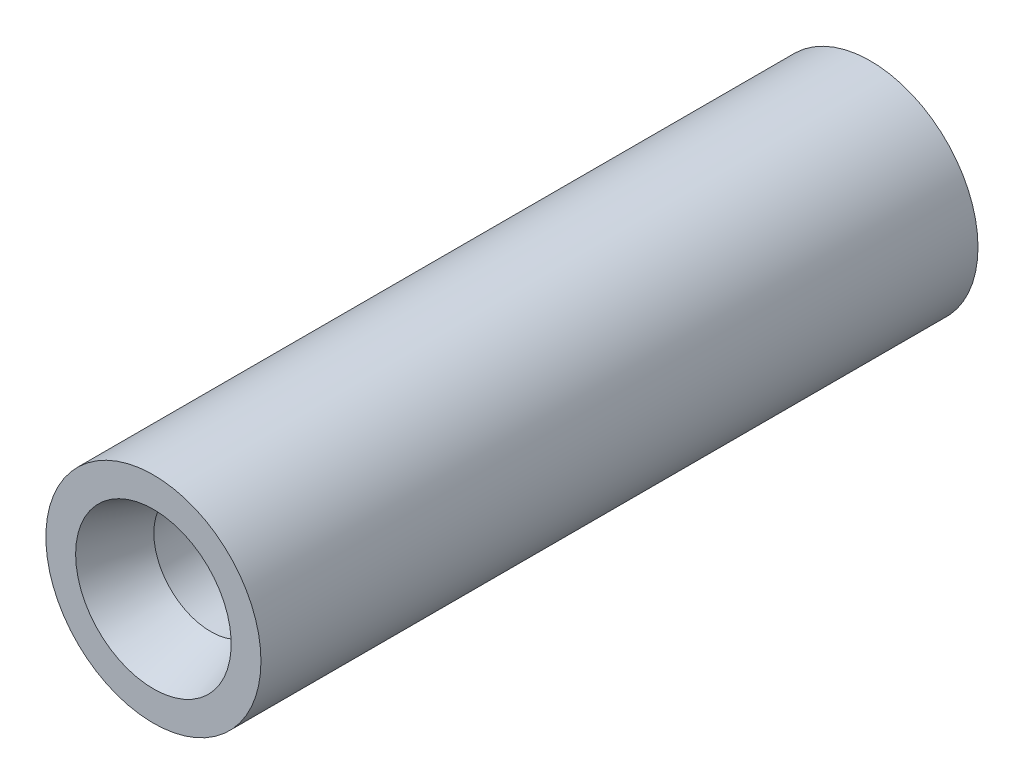
from build123d import *

# Parameters (mm, degrees)
SKIZZE1_R                       = 15
AUFSATZ_LINEAR_AUSTRAGEN1_DEPTH = 100


with BuildPart() as part:
    # Skizze1 → Aufsatz-Linear austragen1 (new body)
    with BuildSketch(Plane.XY):
        Circle(SKIZZE1_R)
    extrude(amount=AUFSATZ_LINEAR_AUSTRAGEN1_DEPTH)

    # Skizze3 → Schnitt-Rotation1 (revolve, cut)
    with BuildSketch(Plane(origin=(0, 0, 0), x_dir=(0, 0, -1), z_dir=(1, 0, 0)), mode=Mode.PRIVATE) as schnitt_rotation1_sk:
        Polygon((-100, 0), (-100, 10.849261874), (-92, 7.9375), (-72, 7.9375), (-66.746283358, 0), align=None)
    revolve(schnitt_rotation1_sk.sketch.rotate(Axis((0, 0, 0), (0, 0, 1)), 270), axis=Axis((0, 0, 0), (0, 0, 1)), mode=Mode.SUBTRACT)  # turned: the seam where the file's is


solid = part.part
